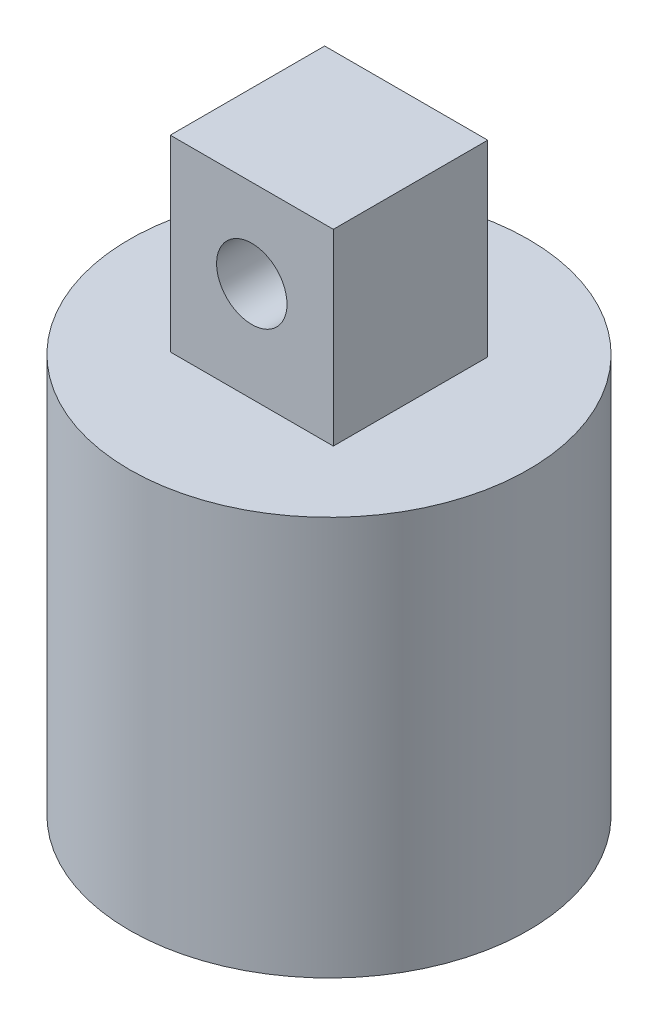
from build123d import *

# Parameters (mm, degrees)
SKETCH1_R           = 8.5
BOSS_EXTRUDE1_DEPTH = 2
SKETCH2_W           = 6.948756548
SKETCH2_H           = 6.57893477
BOSS_EXTRUDE2_DEPTH = 8
SKETCH3_R           = 1.5
CUT_EXTRUDE1_DEPTH  = 8
BOSS_EXTRUDE3_START = -15
SKETCH1_2_R         = 8.5
BOSS_EXTRUDE3_DEPTH = 15
SKETCH5_R           = 7
CUT_EXTRUDE2_DEPTH  = 15


with BuildPart() as part:
    # Sketch1 → Boss-Extrude1 (new body)
    with BuildSketch(Plane(origin=(0, 0, 0), x_dir=(1, 0, 0), z_dir=(0, 1, 0))):
        Circle(SKETCH1_R)
    extrude(amount=BOSS_EXTRUDE1_DEPTH)

    # Sketch2 → Boss-Extrude2 (add)
    with BuildSketch(Plane(origin=(0, 2, 0), x_dir=(1, 0, 0), z_dir=(0, 1, 0))):
        Rectangle(SKETCH2_W, SKETCH2_H)
    extrude(amount=BOSS_EXTRUDE2_DEPTH)

    # Sketch3 → Cut-Extrude1 (cut)
    with BuildSketch(Plane.XY.offset(3.289467385)):
        with Locations((0, 6.248369683)):
            Circle(SKETCH3_R)
    extrude(amount=-CUT_EXTRUDE1_DEPTH, mode=Mode.SUBTRACT)

    # Sketch1_2 → Boss-Extrude3 (add)
    with BuildSketch(Plane(origin=(0, 0, 0), x_dir=(1, 0, 0), z_dir=(0, 1, 0)).offset(BOSS_EXTRUDE3_START)):
        Circle(SKETCH1_2_R)
    extrude(amount=BOSS_EXTRUDE3_DEPTH)

    # Sketch5 → Cut-Extrude2 (cut)
    with BuildSketch(Plane(origin=(0, -15, 0), x_dir=(-1, 0, 0), z_dir=(0, -1, 0))):
        Circle(SKETCH5_R)
    extrude(amount=-CUT_EXTRUDE2_DEPTH, mode=Mode.SUBTRACT)


solid = part.part
